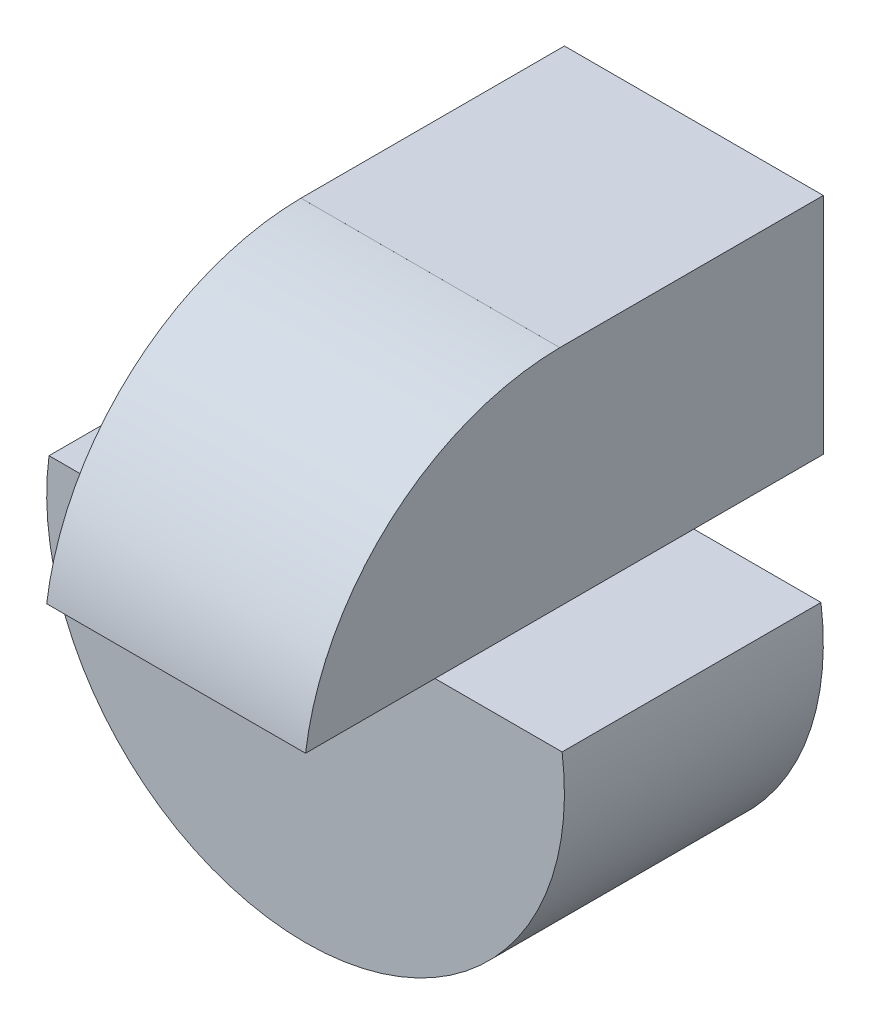
from build123d import *

# Parameters (mm, degrees)
SKETCH1_W           = 40
SKETCH1_H           = 40
BOSS_EXTRUDE1_DEPTH = 40
SKETCH2_W           = 10
SKETCH2_H           = 20
CUT_EXTRUDE1_DEPTH  = 40
SKETCH3_W           = 10
SKETCH3_H           = 10
CUT_EXTRUDE2_DEPTH  = 40
CUT_EXTRUDE3_DEPTH  = 40
SKETCH5_W           = 20
SKETCH5_H           = 10
CUT_EXTRUDE4_DEPTH  = 40
SKETCH6_W           = 20
SKETCH6_H           = 19.641016119
CUT_EXTRUDE5_DEPTH  = 40
BOSS_EXTRUDE2_DEPTH = 20


with BuildPart() as part:
    # Sketch1 → Boss-Extrude1 (new body)
    with BuildSketch(Plane.XY):
        with Locations((20, 20)):
            Rectangle(SKETCH1_W, SKETCH1_H)
    extrude(amount=BOSS_EXTRUDE1_DEPTH)

    # Sketch2 → Cut-Extrude1 (cut)
    with BuildSketch(Plane.XY.offset(40)):
        with BuildLine():
            ThreePointArc((20, 0), (5.857864376, 5.857864376), (0, 20))
            Line((0, 20), (0, 0))
            Line((0, 0), (20, 0))
        make_face()
        with BuildLine():
            ThreePointArc((40, 20), (34.142135624, 5.857864376), (20, 0))
            Line((20, 0), (40, 0))
            Line((40, 0), (40, 20))
        make_face()
        with Locations((35, 30)):
            Rectangle(SKETCH2_W, SKETCH2_H)
        with Locations((5, 30)):
            Rectangle(SKETCH2_W, SKETCH2_H)
    extrude(amount=-CUT_EXTRUDE1_DEPTH, mode=Mode.SUBTRACT)

    # Sketch3 → Cut-Extrude2 (cut)
    with BuildSketch(Plane(origin=(0, 20, 0), x_dir=(1, 0, 0), z_dir=(0, 1, 0))):
        with Locations((5, -5)):
            Rectangle(SKETCH3_W, SKETCH3_H)
        with Locations((35, -5)):
            Rectangle(SKETCH3_W, SKETCH3_H)
        with Locations((35, -35)):
            Rectangle(SKETCH3_W, SKETCH3_H)
        with Locations((5, -35)):
            Rectangle(SKETCH3_W, SKETCH3_H)
    extrude(amount=-CUT_EXTRUDE2_DEPTH, mode=Mode.SUBTRACT)

    # Sketch4 → Cut-Extrude3 (cut)
    with BuildSketch(Plane.ZY.offset(-10)):
        Polygon((10, 22.679491924), (0, 22.679491924), (0, 2.679491924), (10, 2.679491924), (10, 20), align=None)
        Polygon((30, 2.679491924), (40, 2.679491924), (40, 22.679491924), (30, 22.679491924), (30, 20), align=None)
        with BuildLine():
            ThreePointArc((20.358983897, 39.999201827), (33.408185604, 35.000772179), (40, 22.679491924))
            Line((40, 22.679491924), (40, 40))
            Line((40, 40), (20.358983897, 39.999201827))
        make_face()
    extrude(amount=-CUT_EXTRUDE3_DEPTH, mode=Mode.SUBTRACT)

    # Sketch5 → Cut-Extrude4 (cut)
    with BuildSketch(Plane(origin=(0, 2.679491924, 0), x_dir=(1, 0, 0), z_dir=(0, 1, 0))):
        with Locations((20, -5)):
            Rectangle(SKETCH5_W, SKETCH5_H)
        with Locations((20, -35)):
            Rectangle(SKETCH5_W, SKETCH5_H)
    extrude(amount=-CUT_EXTRUDE4_DEPTH, mode=Mode.SUBTRACT)

    # Sketch6 → Cut-Extrude5 (cut)
    with BuildSketch(Plane(origin=(0, 39.998374412, -0.001625456), x_dir=(1, 0, 0), z_dir=(0, -0.999999999, 4.0638e-05))):
        with Locations((20, 30.18111743)):
            Rectangle(SKETCH6_W, SKETCH6_H)
    extrude(amount=-CUT_EXTRUDE5_DEPTH, mode=Mode.SUBTRACT)

    # Sketch8 → Boss-Extrude2 (add)
    with BuildSketch(Plane.XY.offset(30)):
        with BuildLine():
            Line((0.180304669, 22.679491924), (39.819695331, 22.679491924))
            ThreePointArc((39.819695331, 22.679491924), (20, 0), (0.180304669, 22.679491924))
        make_face()
    extrude(amount=-BOSS_EXTRUDE2_DEPTH)


solid = part.part
